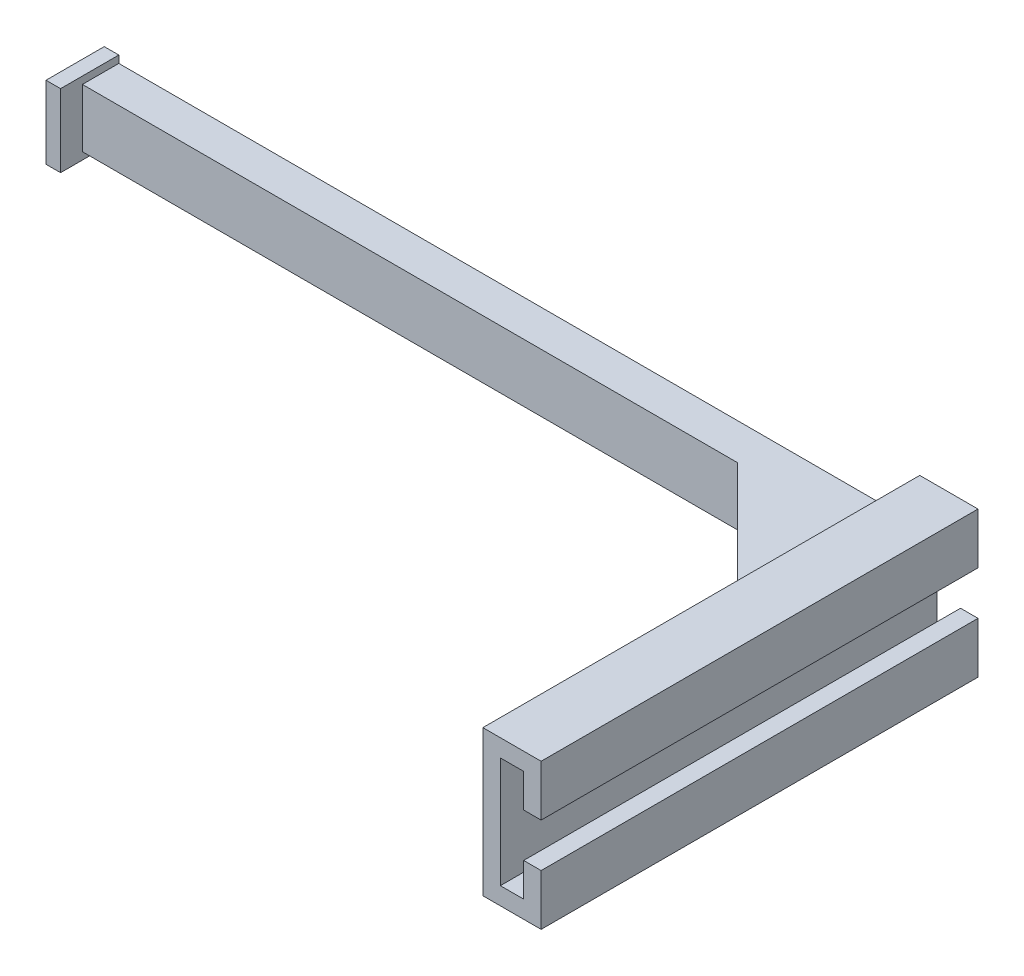
from build123d import *

# Parameters (mm, degrees)
EXTRUDE_1_DEPTH     = 60
SKETCH_2_W          = 5
SKETCH_2_H          = 8
EXTRUDE_2_DEPTH     = 197
CHAMFER_1_SIZE      = 20
CHAMFER_2_SIZE      = 2
SKETCH_4_W          = 85
SKETCH_4_H          = 8
CUT_EXTRUDE_1_DEPTH = 10
SKETCH_5_W          = 8
SKETCH_5_H          = 10
EXTRUDE_3_DEPTH     = 2


with BuildPart() as part:
    # 草图1 → 凸台-拉伸1 (new body)
    with BuildSketch(Plane.XY):
        Polygon((5.6, 10.6), (3.2, 10.6), (3.2, 15.2), (0, 15.2), (0, 0), (3.2, 0), (3.2, 4.6), (5.6, 4.6), (5.6, -2.4), (-2.4, -2.4), (-2.4, 17.6), (5.6, 17.6), align=None)
    extrude(amount=EXTRUDE_1_DEPTH)

    # 草图2 → 凸台-拉伸2 (add)
    with BuildSketch(Plane.ZY.offset(2.4)):
        with Locations((2.5, 7.6)):
            Rectangle(SKETCH_2_W, SKETCH_2_H)
    extrude(amount=EXTRUDE_2_DEPTH)

    # 倒角1
    chamfer_1_edges = [part.edges().sort_by_distance(p)[0] for p in [
        (-2.4, 7.6, 5),
    ]]
    chamfer(chamfer_1_edges, length=CHAMFER_1_SIZE)

    # 倒角2
    chamfer_2_edges = [part.edges().sort_by_distance(p)[0] for p in [
        (-2.4, 3.6, 15),
        (-2.4, 11.6, 15),
    ]]
    chamfer(chamfer_2_edges, length=CHAMFER_2_SIZE)

    # 草图4 → 切除-拉伸1 (cut)
    with BuildSketch(Plane(origin=(0, 0, 0), x_dir=(-1, 0, 0), z_dir=(0, 0, -1))):
        with Locations((156.9, 7.6)):
            Rectangle(SKETCH_4_W, SKETCH_4_H)
    extrude(amount=-CUT_EXTRUDE_1_DEPTH, mode=Mode.SUBTRACT)

    # 草图5 → 凸台-拉伸3 (add)
    with BuildSketch(Plane.ZY.offset(114.4)):
        with Locations((4, 7.6)):
            Rectangle(SKETCH_5_W, SKETCH_5_H)
    extrude(amount=-EXTRUDE_3_DEPTH)


solid = part.part
